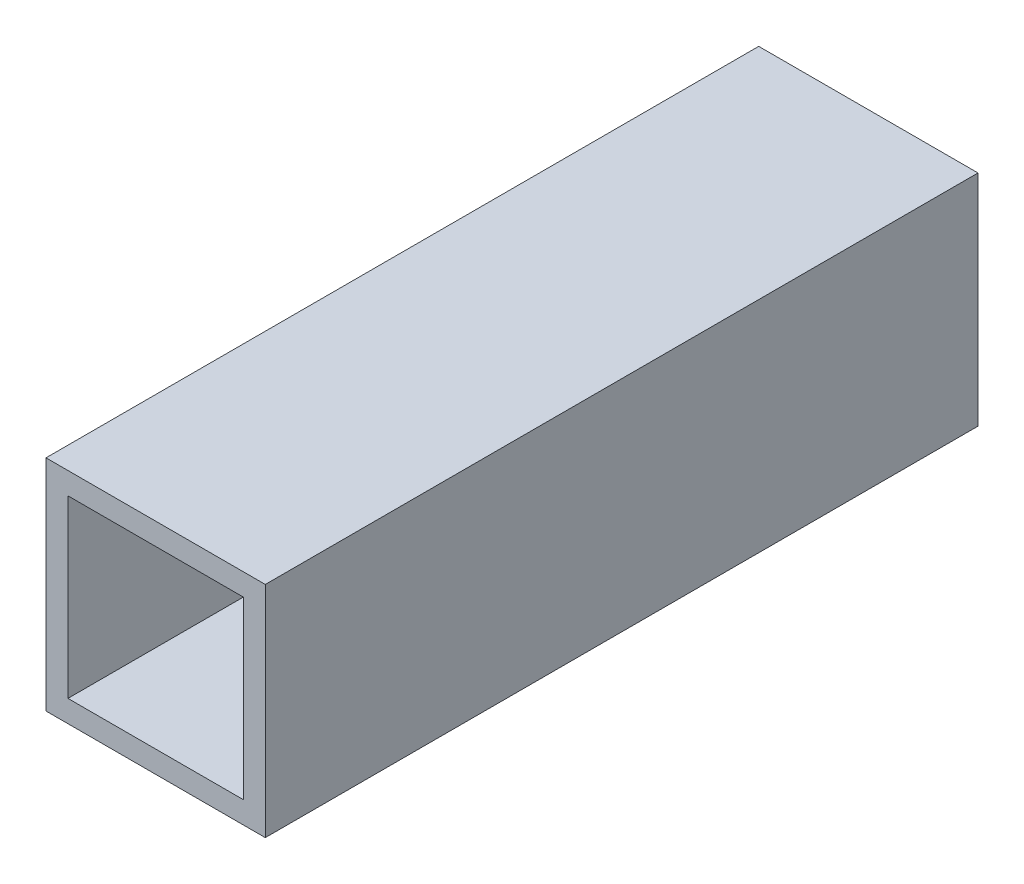
from build123d import *

# Parameters (mm, degrees)
IZIM1_W                     = 40
IZIM1_H                     = 40
IZIM1_W_2                   = 32
IZIM1_H_2                   = 32
Y_KSEKLIK_EKSTR_ZYON1_DEPTH = 130


with BuildPart() as part:
    # Çizim1 → Yükseklik-Ekstrüzyon1 (new body)
    with BuildSketch(Plane.XY):
        with Locations((20, 20)):
            Rectangle(IZIM1_W, IZIM1_H)
        with Locations((20, 20)):
            Rectangle(IZIM1_W_2, IZIM1_H_2, mode=Mode.SUBTRACT)
    extrude(amount=Y_KSEKLIK_EKSTR_ZYON1_DEPTH)


solid = part.part
